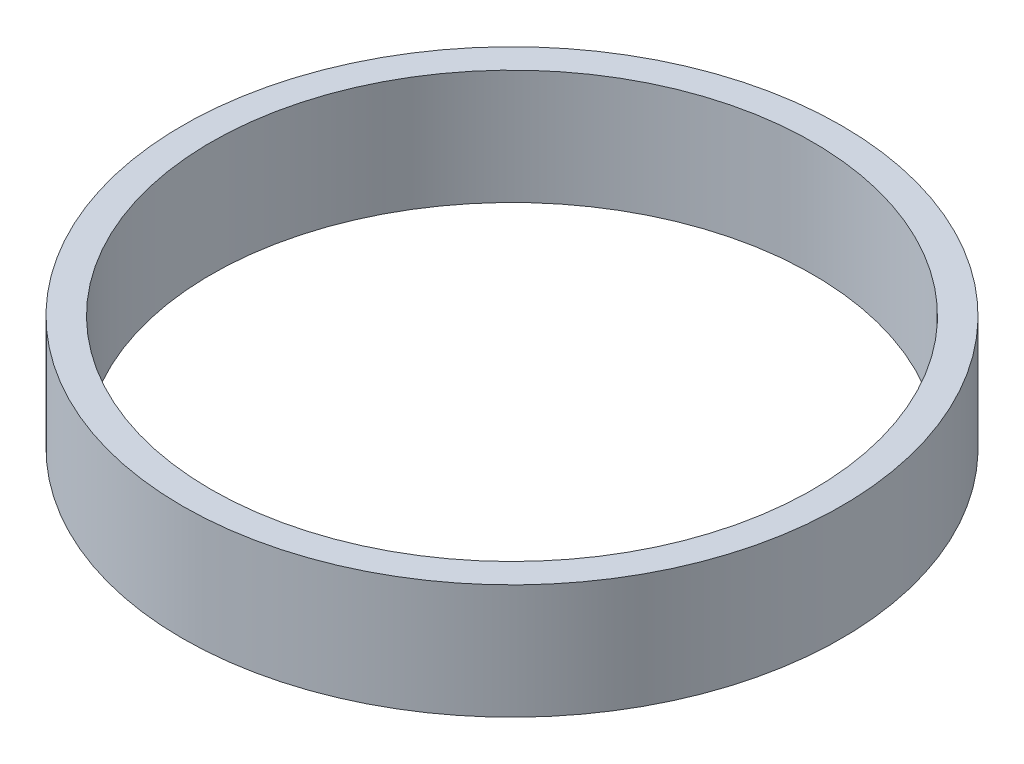
from build123d import *

# Parameters (mm, degrees)
SKETCH1_R           = 11.5
SKETCH1_R_2         = 10.5
BOSS_EXTRUDE1_DEPTH = 4


with BuildPart() as part:
    # Sketch1 → Boss-Extrude1 (new body)
    with BuildSketch(Plane(origin=(0, 0, 0), x_dir=(1, 0, 0), z_dir=(0, 1, 0))):
        Circle(SKETCH1_R)
        Circle(SKETCH1_R_2, mode=Mode.SUBTRACT)
    extrude(amount=BOSS_EXTRUDE1_DEPTH)


solid = part.part
